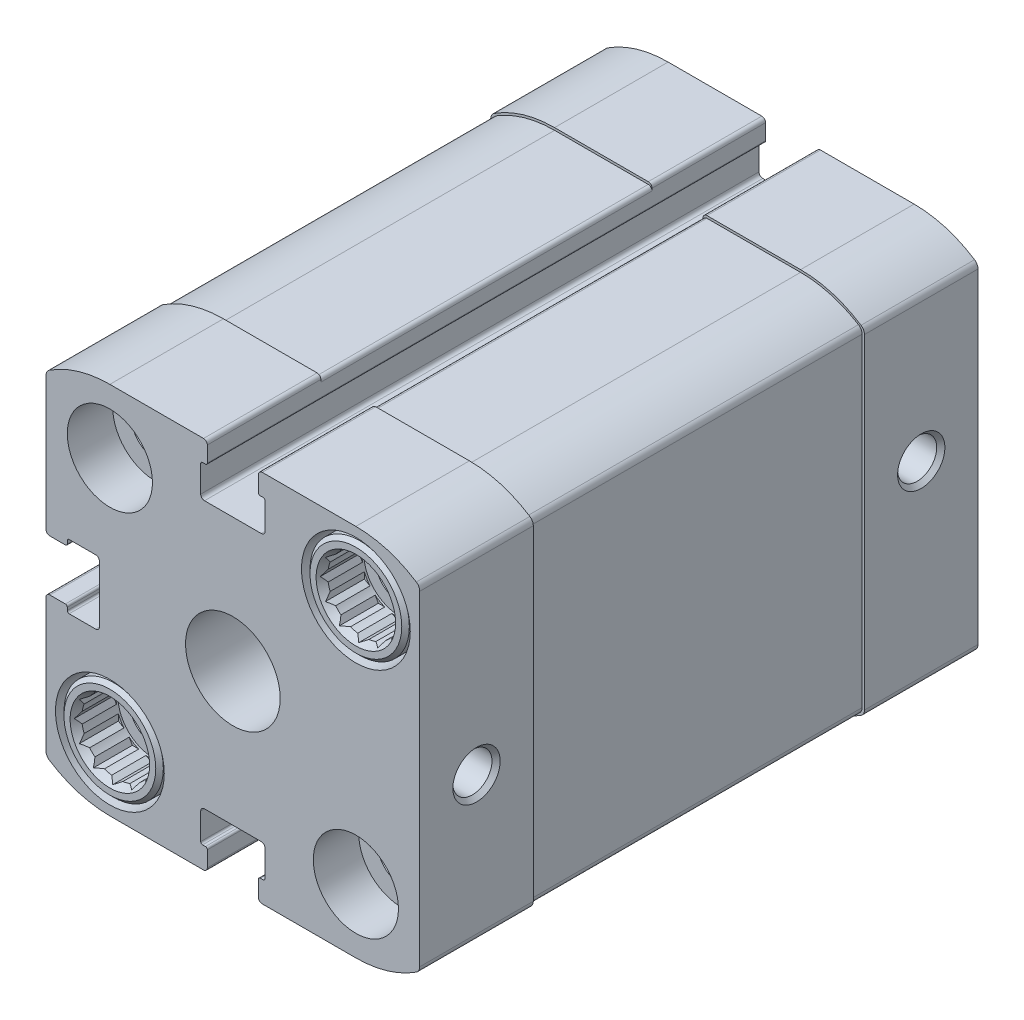
from build123d import *

# Parameters (mm, degrees)
AUFSATZ_LINEAR_AUSTRAGEN1_DEPTH = 59
SKIZZE2_W                       = 79
SKIZZE2_H                       = 79
SCHNITT_LINEAR_AUSTRAGEN1_DEPTH = 35
BOHRUNG1_D                      = 4.134
BOHRUNG1_DEPTH                  = 11
BOHRUNG1_CSINK_D                = 5
BOHRUNG1_CSINK_ANGLE            = 90
BOHRUNG2_D                      = 4.134
BOHRUNG2_DEPTH                  = 11
BOHRUNG2_CSINK_D                = 5
BOHRUNG2_CSINK_ANGLE            = 90
BOHRUNG3_D                      = 9
BOHRUNG3_DEPTH                  = 2.1
BOHRUNG4_D                      = 7
BOHRUNG4_DEPTH                  = 19.5
BOHRUNG4_CBORE_D                = 11.5
BOHRUNG4_CBORE_DEPTH            = 6.5
BOHRUNG5_D                      = 7
BOHRUNG5_DEPTH                  = 19.5
BOHRUNG5_CBORE_D                = 11.5
BOHRUNG5_CBORE_DEPTH            = 6.5
BOHRUNG6_D                      = 7
BOHRUNG6_DEPTH                  = 19.5
BOHRUNG6_CBORE_D                = 11.5
BOHRUNG6_CBORE_DEPTH            = 6.5
BOHRUNG7_D                      = 7
BOHRUNG7_DEPTH                  = 19.5
BOHRUNG7_CBORE_D                = 11.5
BOHRUNG7_CBORE_DEPTH            = 6.5
SKIZZE23_W                      = 27.5
SKIZZE23_H                      = 4.5
SKIZZE24_W                      = 2.5
SKIZZE24_H                      = 27.5
SKIZZE27_W                      = 27.5
SKIZZE27_H                      = 4.5
SKIZZE28_W                      = 2.5
SKIZZE28_H                      = 27.5
SKIZZE31_W                      = 27.5
SKIZZE31_H                      = 4.5
SKIZZE32_W                      = 2.5
SKIZZE32_H                      = 27.5
SKIZZE35_W                      = 27.5
SKIZZE35_H                      = 4.5
SKIZZE36_W                      = 2.5
SKIZZE36_H                      = 27.5
SCHNITT_LINEAR_AUSTRAGEN2_DEPTH = 4.4
SCHNITT_LINEAR_AUSTRAGEN3_DEPTH = 4.4
SCHNITT_LINEAR_AUSTRAGEN4_DEPTH = 4.4
SCHNITT_LINEAR_AUSTRAGEN5_DEPTH = 4.4


with BuildPart() as part:
    # Skizze1 → Aufsatz-Linear austragen1 (new body)
    with BuildSketch(Plane.XY):
        with BuildLine():
            Line((-19.75, -3.1), (-19.75, -17.182770664))
            ThreePointArc((-19.75, -17.182770664), (-19.653334114, -17.563980742), (-19.38669719, -17.853065796))
            ThreePointArc((-19.38669719, -17.853065796), (-16.331225765, -19.265744955), (-13, -19.75))
            Line((-13, -19.75), (-3.1, -19.75))
            ThreePointArc((-3.1, -19.75), (-2.817157288, -19.632842712), (-2.7, -19.35))
            Line((-2.7, -19.35), (-2.7, -17.7))
            ThreePointArc((-2.7, -17.7), (-2.758578644, -17.558578644), (-2.9, -17.5))
            Line((-2.9, -17.5), (-3.2, -17.5))
            ThreePointArc((-3.2, -17.5), (-3.341421356, -17.441421356), (-3.4, -17.3))
            Line((-3.4, -17.3), (-3.4, -14.5))
            ThreePointArc((-3.4, -14.5), (-3.282842712, -14.217157288), (-3, -14.1))
            Line((-3, -14.1), (3, -14.1))
            ThreePointArc((3, -14.1), (3.282842712, -14.217157288), (3.4, -14.5))
            Line((3.4, -14.5), (3.4, -17.3))
            ThreePointArc((3.4, -17.3), (3.341421356, -17.441421356), (3.2, -17.5))
            Line((3.2, -17.5), (2.9, -17.5))
            ThreePointArc((2.9, -17.5), (2.758578644, -17.558578644), (2.7, -17.7))
            Line((2.7, -17.7), (2.7, -19.35))
            ThreePointArc((2.7, -19.35), (2.817157288, -19.632842712), (3.1, -19.75))
            Line((3.1, -19.75), (13, -19.75))
            ThreePointArc((13, -19.75), (16.331225797, -19.265744946), (19.386697248, -17.853065759))
            ThreePointArc((19.386697248, -17.853065759), (19.65333413, -17.563980712), (19.75, -17.182770664))
            Line((19.75, -17.182770664), (19.75, 17.182770664))
            ThreePointArc((19.75, 17.182770664), (19.65333413, 17.563980712), (19.386697248, 17.853065759))
            ThreePointArc((19.386697248, 17.853065759), (16.331225797, 19.265744946), (13, 19.75))
            Line((13, 19.75), (3.1, 19.75))
            ThreePointArc((3.1, 19.75), (2.817157288, 19.632842712), (2.7, 19.35))
            Line((2.7, 19.35), (2.7, 17.7))
            ThreePointArc((2.7, 17.7), (2.758578644, 17.558578644), (2.9, 17.5))
            Line((2.9, 17.5), (3.2, 17.5))
            ThreePointArc((3.2, 17.5), (3.341421356, 17.441421356), (3.4, 17.3))
            Line((3.4, 17.3), (3.4, 14.5))
            ThreePointArc((3.4, 14.5), (3.282842712, 14.217157288), (3, 14.1))
            Line((3, 14.1), (-3, 14.1))
            ThreePointArc((-3, 14.1), (-3.282842712, 14.217157288), (-3.4, 14.5))
            Line((-3.4, 14.5), (-3.4, 17.3))
            ThreePointArc((-3.4, 17.3), (-3.341421356, 17.441421356), (-3.2, 17.5))
            Line((-3.2, 17.5), (-2.9, 17.5))
            ThreePointArc((-2.9, 17.5), (-2.758578644, 17.558578644), (-2.7, 17.7))
            Line((-2.7, 17.7), (-2.7, 19.35))
            ThreePointArc((-2.7, 19.35), (-2.817157288, 19.632842712), (-3.1, 19.75))
            Line((-3.1, 19.75), (-13, 19.75))
            ThreePointArc((-13, 19.75), (-16.331225797, 19.265744946), (-19.386697248, 17.853065759))
            ThreePointArc((-19.386697248, 17.853065759), (-19.65333413, 17.563980712), (-19.75, 17.182770664))
            Line((-19.75, 17.182770664), (-19.75, 3.1))
            ThreePointArc((-19.75, 3.1), (-19.632842712, 2.817157288), (-19.35, 2.7))
            Line((-19.35, 2.7), (-17.7, 2.7))
            ThreePointArc((-17.7, 2.7), (-17.558578644, 2.758578644), (-17.5, 2.9))
            Line((-17.5, 2.9), (-17.5, 3.2))
            ThreePointArc((-17.5, 3.2), (-17.441421356, 3.341421356), (-17.3, 3.4))
            Line((-17.3, 3.4), (-14.5, 3.4))
            ThreePointArc((-14.5, 3.4), (-14.217157288, 3.282842712), (-14.1, 3))
            Line((-14.1, 3), (-14.1, -3))
            ThreePointArc((-14.1, -3), (-14.217157288, -3.282842712), (-14.5, -3.4))
            Line((-14.5, -3.4), (-17.3, -3.4))
            ThreePointArc((-17.3, -3.4), (-17.441421356, -3.341421356), (-17.5, -3.2))
            Line((-17.5, -3.2), (-17.5, -2.9))
            ThreePointArc((-17.5, -2.9), (-17.558578644, -2.758578644), (-17.7, -2.7))
            Line((-17.7, -2.7), (-19.35, -2.7))
            ThreePointArc((-19.35, -2.7), (-19.632842712, -2.817157288), (-19.75, -3.1))
        make_face()
    extrude(amount=-AUFSATZ_LINEAR_AUSTRAGEN1_DEPTH)

    # Skizze2 → Schnitt-Linear austragen1 (cut)
    with BuildSketch(Plane.XY.offset(-12)):
        Rectangle(SKIZZE2_W, SKIZZE2_H)
        with BuildLine():
            Line((-19.5, -3.1), (-19.5, -17.090855719))
            ThreePointArc((-19.5, -17.090855719), (-19.39809702, -17.481573713), (-19.118348624, -17.772753387))
            ThreePointArc((-19.118348624, -17.772753387), (-16.178740739, -19.059911514), (-13, -19.5))
            Line((-13, -19.5), (-3.1, -19.5))
            ThreePointArc((-3.1, -19.5), (-2.817157288, -19.382842712), (-2.7, -19.1))
            Line((-2.7, -19.1), (-2.7, -17.65))
            ThreePointArc((-2.7, -17.65), (-2.743933983, -17.543933983), (-2.85, -17.5))
            Line((-2.85, -17.5), (-3.2, -17.5))
            ThreePointArc((-3.2, -17.5), (-3.341421356, -17.441421356), (-3.4, -17.3))
            Line((-3.4, -17.3), (-3.4, -14.5))
            ThreePointArc((-3.4, -14.5), (-3.282842712, -14.217157288), (-3, -14.1))
            Line((-3, -14.1), (3, -14.1))
            ThreePointArc((3, -14.1), (3.282842712, -14.217157288), (3.4, -14.5))
            Line((3.4, -14.5), (3.4, -17.3))
            ThreePointArc((3.4, -17.3), (3.341421356, -17.441421356), (3.2, -17.5))
            Line((3.2, -17.5), (2.85, -17.5))
            ThreePointArc((2.85, -17.5), (2.743933983, -17.543933983), (2.7, -17.65))
            Line((2.7, -17.65), (2.7, -19.1))
            ThreePointArc((2.7, -19.1), (2.817157288, -19.382842712), (3.1, -19.5))
            Line((3.1, -19.5), (13, -19.5))
            ThreePointArc((13, -19.5), (16.178740739, -19.059911514), (19.118348624, -17.772753387))
            ThreePointArc((19.118348624, -17.772753387), (19.39809702, -17.481573713), (19.5, -17.090855719))
            Line((19.5, -17.090855719), (19.5, 17.090855719))
            ThreePointArc((19.5, 17.090855719), (19.39809702, 17.481573713), (19.118348624, 17.772753387))
            ThreePointArc((19.118348624, 17.772753387), (16.178740739, 19.059911514), (13, 19.5))
            Line((13, 19.5), (3.1, 19.5))
            ThreePointArc((3.1, 19.5), (2.817157288, 19.382842712), (2.7, 19.1))
            Line((2.7, 19.1), (2.7, 17.65))
            ThreePointArc((2.7, 17.65), (2.743933983, 17.543933983), (2.85, 17.5))
            Line((2.85, 17.5), (3.2, 17.5))
            ThreePointArc((3.2, 17.5), (3.341421356, 17.441421356), (3.4, 17.3))
            Line((3.4, 17.3), (3.4, 14.5))
            ThreePointArc((3.4, 14.5), (3.282842712, 14.217157288), (3, 14.1))
            Line((3, 14.1), (-3, 14.1))
            ThreePointArc((-3, 14.1), (-3.282842712, 14.217157288), (-3.4, 14.5))
            Line((-3.4, 14.5), (-3.4, 17.3))
            ThreePointArc((-3.4, 17.3), (-3.341421356, 17.441421356), (-3.2, 17.5))
            Line((-3.2, 17.5), (-2.85, 17.5))
            ThreePointArc((-2.85, 17.5), (-2.743933983, 17.543933983), (-2.7, 17.65))
            Line((-2.7, 17.65), (-2.7, 19.1))
            ThreePointArc((-2.7, 19.1), (-2.817157288, 19.382842712), (-3.1, 19.5))
            Line((-3.1, 19.5), (-13, 19.5))
            ThreePointArc((-13, 19.5), (-16.178740739, 19.059911514), (-19.118348624, 17.772753387))
            ThreePointArc((-19.118348624, 17.772753387), (-19.39809702, 17.481573713), (-19.5, 17.090855719))
            Line((-19.5, 17.090855719), (-19.5, 3.1))
            ThreePointArc((-19.5, 3.1), (-19.382842712, 2.817157288), (-19.1, 2.7))
            Line((-19.1, 2.7), (-17.65, 2.7))
            ThreePointArc((-17.65, 2.7), (-17.543933983, 2.743933983), (-17.5, 2.85))
            Line((-17.5, 2.85), (-17.5, 3.2))
            ThreePointArc((-17.5, 3.2), (-17.441421356, 3.341421356), (-17.3, 3.4))
            Line((-17.3, 3.4), (-14.5, 3.4))
            ThreePointArc((-14.5, 3.4), (-14.217157288, 3.282842712), (-14.1, 3))
            Line((-14.1, 3), (-14.1, -3))
            ThreePointArc((-14.1, -3), (-14.217157288, -3.282842712), (-14.5, -3.4))
            Line((-14.5, -3.4), (-17.3, -3.4))
            ThreePointArc((-17.3, -3.4), (-17.441421356, -3.341421356), (-17.5, -3.2))
            Line((-17.5, -3.2), (-17.5, -2.85))
            ThreePointArc((-17.5, -2.85), (-17.543933983, -2.743933983), (-17.65, -2.7))
            Line((-17.65, -2.7), (-19.1, -2.7))
            ThreePointArc((-19.1, -2.7), (-19.382842712, -2.817157288), (-19.5, -3.1))
        make_face(mode=Mode.SUBTRACT)
    extrude(amount=-SCHNITT_LINEAR_AUSTRAGEN1_DEPTH, mode=Mode.SUBTRACT)

    # Bohrung1
    with Locations(Plane(origin=(19.75, 0, 0), x_dir=(0, 0, -1), z_dir=(1, 0, 0))):
        with Locations((6, -2.6)):
            CounterSinkHole(BOHRUNG1_D / 2, BOHRUNG1_CSINK_D / 2, depth=BOHRUNG1_DEPTH, counter_sink_angle=BOHRUNG1_CSINK_ANGLE)

    # Bohrung2
    with Locations(Plane(origin=(19.75, 0, 0), x_dir=(0, 0, -1), z_dir=(1, 0, 0))):
        with Locations((53, 2.6)):
            CounterSinkHole(BOHRUNG2_D / 2, BOHRUNG2_CSINK_D / 2, depth=BOHRUNG2_DEPTH, counter_sink_angle=BOHRUNG2_CSINK_ANGLE)

    # Skizze7 → Schnitt-Rotation1 (revolve, cut)
    with BuildSketch(Plane(origin=(0, 0, 0), x_dir=(0, 0, -1), z_dir=(1, 0, 0))):
        Polygon((-12.2, 0), (-12.2, 5), (20.75, 5), (20.75, 12.5), (47, 12.5), (47, 0), align=None)
    revolve(axis=Axis((0, 0, -47), (0, 0, 1)), mode=Mode.SUBTRACT)

    # Bohrung3
    with Locations(Plane(origin=(0, 0, -59), x_dir=(-1, 0, 0), z_dir=(0, 0, -1))):
        with Locations((0, 0)):
            Hole(BOHRUNG3_D / 2, depth=BOHRUNG3_DEPTH)

    # Bohrung4
    with Locations(Plane.XY):
        with Locations((13, 13)):
            CounterBoreHole(BOHRUNG4_D / 2, BOHRUNG4_CBORE_D / 2, BOHRUNG4_CBORE_DEPTH, depth=BOHRUNG4_DEPTH)

    # Skizze12 → Rotation1 (revolve)
    with BuildSketch(Plane(origin=(13, 0, 0), x_dir=(0, 0, -1), z_dir=(1, 0, 0))):
        Polygon((0, 17.2), (0.779422863, 16.75), (4.6, 16.75), (4.6, 15.5), (5.033, 15.067), (19.5, 15.067), (19.5, 17.5), (6.5, 17.5), (6.5, 18.25), (0.4, 18.25), (0, 17.85), align=None)
    revolve(axis=Axis((13, 13, -19.5), (0, 0, 1)))

    # Bohrung5
    with Locations(Plane(origin=(0, 0, -59), x_dir=(-1, 0, 0), z_dir=(0, 0, -1))):
        with Locations((-13, -13)):
            CounterBoreHole(BOHRUNG5_D / 2, BOHRUNG5_CBORE_D / 2, BOHRUNG5_CBORE_DEPTH, depth=BOHRUNG5_DEPTH)

    # Skizze15 → Rotation2 (revolve)
    with BuildSketch(Plane(origin=(13, 0, 0), x_dir=(0, 0, -1), z_dir=(1, 0, 0))):
        Polygon((39.5, -8.5), (39.5, -10.933), (53.967, -10.933), (54.4, -10.5), (54.4, -9.25), (58.220577137, -9.25), (59, -8.8), (59, -8.15), (58.6, -7.75), (52.5, -7.75), (52.5, -8.5), align=None)
    revolve(axis=Axis((13, -13, -59), (0, 0, 1)))

    # Bohrung6
    with Locations(Plane.XY):
        with Locations((-13, -13)):
            CounterBoreHole(BOHRUNG6_D / 2, BOHRUNG6_CBORE_D / 2, BOHRUNG6_CBORE_DEPTH, depth=BOHRUNG6_DEPTH)

    # Bohrung7
    with Locations(Plane(origin=(0, 0, -59), x_dir=(-1, 0, 0), z_dir=(0, 0, -1))):
        with Locations((13, 13)):
            CounterBoreHole(BOHRUNG7_D / 2, BOHRUNG7_CBORE_D / 2, BOHRUNG7_CBORE_DEPTH, depth=BOHRUNG7_DEPTH)

    # Skizze20 → Rotation3 (revolve)
    with BuildSketch(Plane(origin=(-13, 0, 0), x_dir=(0, 0, -1), z_dir=(1, 0, 0))):
        Polygon((0, -8.8), (0.779422863, -9.25), (4.6, -9.25), (4.6, -10.5), (5.033, -10.933), (19.5, -10.933), (19.5, -8.5), (6.5, -8.5), (6.5, -7.75), (0.4, -7.75), (0, -8.15), align=None)
    revolve(axis=Axis((-13, -13, -19.5), (0, 0, 1)))

    # Skizze21 → Rotation4 (revolve)
    with BuildSketch(Plane(origin=(-13, 0, 0), x_dir=(0, 0, -1), z_dir=(1, 0, 0))):
        Polygon((39.5, 17.5), (39.5, 15.067), (53.967, 15.067), (54.4, 15.5), (54.4, 16.75), (58.220577137, 16.75), (59, 17.2), (59, 17.85), (58.6, 18.25), (52.5, 18.25), (52.5, 17.5), align=None)
    revolve(axis=Axis((-13, 13, -59), (0, 0, 1)))

    # Skizze22 → Schnitt-Rotation2 (revolve, cut)
    with BuildSketch(Plane(origin=(13, 0, 0), x_dir=(0, 0, -1), z_dir=(1, 0, 0))):
        Polygon((-0.1, -13), (-0.1, -8.5), (4.8, -8.5), (4.8, -10.5), (5.233, -10.933), (39.5, -10.933), (39.5, -13), align=None)
    revolve(axis=Axis((13, -13, -39.5), (0, 0, 1)), mode=Mode.SUBTRACT)

    # Skizze23 → Rotation5 (revolve)
    with BuildSketch(Plane(origin=(13, 0, 0), x_dir=(0, 0, -1), z_dir=(1, 0, 0))):
        with Locations((25.75, -10.75)):
            Rectangle(SKIZZE23_W, SKIZZE23_H)
    revolve(axis=Axis((13, -13, -39.5), (0, 0, 1)))

    # Skizze24 → Bohrung8 (revolve, cut)
    with BuildSketch(Plane(origin=(13, -13, -39.5), x_dir=(0, 1, 0), z_dir=(1, 0, 0))):
        with Locations((1.25, 13.75)):
            Rectangle(SKIZZE24_W, SKIZZE24_H)
    revolve(axis=Axis((13, -13, 70.5), (0, 0, -1)), mode=Mode.SUBTRACT)

    # Skizze26 → Schnitt-Rotation3 (revolve, cut)
    with BuildSketch(Plane(origin=(13, 0, 0), x_dir=(0, 0, -1), z_dir=(1, 0, 0))):
        Polygon((29.5, 13), (29.5, 15.067), (53.767, 15.067), (54.2, 15.5), (54.2, 17.5), (59.1, 17.5), (59.1, 13), align=None)
    revolve(axis=Axis((13, 13, -59.1), (0, 0, 1)), mode=Mode.SUBTRACT)

    # Skizze27 → Rotation6 (revolve)
    with BuildSketch(Plane(origin=(13, 0, 0), x_dir=(0, 0, -1), z_dir=(1, 0, 0))):
        with Locations((33.25, 15.25)):
            Rectangle(SKIZZE27_W, SKIZZE27_H)
    revolve(axis=Axis((13, 13, -47), (0, 0, 1)))

    # Skizze28 → Bohrung9 (revolve, cut)
    with BuildSketch(Plane(origin=(13, 13, -47), x_dir=(0, 1, 0), z_dir=(1, 0, 0))):
        with Locations((1.25, 13.75)):
            Rectangle(SKIZZE28_W, SKIZZE28_H)
    revolve(axis=Axis((13, 13, 63), (0, 0, -1)), mode=Mode.SUBTRACT)

    # Skizze30 → Schnitt-Rotation4 (revolve, cut)
    with BuildSketch(Plane(origin=(-13, 0, 0), x_dir=(0, 0, -1), z_dir=(1, 0, 0))):
        Polygon((-0.1, 13), (-0.1, 17.5), (4.8, 17.5), (4.8, 15.5), (5.233, 15.067), (39.5, 15.067), (39.5, 13), align=None)
    revolve(axis=Axis((-13, 13, -39.5), (0, 0, 1)), mode=Mode.SUBTRACT)

    # Skizze31 → Rotation7 (revolve)
    with BuildSketch(Plane(origin=(-13, 0, 0), x_dir=(0, 0, -1), z_dir=(1, 0, 0))):
        with Locations((25.75, 15.25)):
            Rectangle(SKIZZE31_W, SKIZZE31_H)
    revolve(axis=Axis((-13, 13, -39.5), (0, 0, 1)))

    # Skizze32 → Bohrung10 (revolve, cut)
    with BuildSketch(Plane(origin=(-13, 13, -39.5), x_dir=(0, 1, 0), z_dir=(1, 0, 0))):
        with Locations((1.25, 13.75)):
            Rectangle(SKIZZE32_W, SKIZZE32_H)
    revolve(axis=Axis((-13, 13, 70.5), (0, 0, -1)), mode=Mode.SUBTRACT)

    # Skizze34 → Schnitt-Rotation5 (revolve, cut)
    with BuildSketch(Plane(origin=(-13, 0, 0), x_dir=(0, 0, -1), z_dir=(1, 0, 0))):
        Polygon((29.5, -13), (29.5, -10.933), (53.767, -10.933), (54.2, -10.5), (54.2, -8.5), (59.1, -8.5), (59.1, -13), align=None)
    revolve(axis=Axis((-13, -13, -59.1), (0, 0, 1)), mode=Mode.SUBTRACT)

    # Skizze35 → Rotation8 (revolve)
    with BuildSketch(Plane(origin=(-13, 0, 0), x_dir=(0, 0, -1), z_dir=(1, 0, 0))):
        with Locations((33.25, -10.75)):
            Rectangle(SKIZZE35_W, SKIZZE35_H)
    revolve(axis=Axis((-13, -13, -47), (0, 0, 1)))

    # Skizze36 → Bohrung11 (revolve, cut)
    with BuildSketch(Plane(origin=(-13, -13, -47), x_dir=(0, 1, 0), z_dir=(1, 0, 0))):
        with Locations((1.25, 13.75)):
            Rectangle(SKIZZE36_W, SKIZZE36_H)
    revolve(axis=Axis((-13, -13, 63), (0, 0, -1)), mode=Mode.SUBTRACT)

    # Skizze38 → Schnitt-Linear austragen2 (cut)
    with BuildSketch(Plane.XY):
        Polygon((-17.041451884, -13), (-16.5, -13.937822174), (-16.5, -15.020725942), (-15.562177826, -15.562177826), (-15.020725942, -16.5), (-13.937822174, -16.5), (-13, -17.041451884), (-12.062177826, -16.5), (-10.979274058, -16.5), (-10.437822174, -15.562177826), (-9.5, -15.020725942), (-9.5, -13.937822174), (-8.958548116, -13), (-9.5, -12.062177826), (-9.5, -10.979274058), (-10.437822174, -10.437822174), (-10.979274058, -9.5), (-12.062177826, -9.5), (-13, -8.958548116), (-13.937822174, -9.5), (-15.020725942, -9.5), (-15.562177826, -10.437822174), (-16.5, -10.979274058), (-16.5, -12.062177826), align=None)
    extrude(amount=-SCHNITT_LINEAR_AUSTRAGEN2_DEPTH, mode=Mode.SUBTRACT)

    # Skizze39 → Schnitt-Linear austragen3 (cut)
    with BuildSketch(Plane.XY):
        Polygon((8.958548116, 13), (9.5, 12.062177826), (9.5, 10.979274058), (10.437822174, 10.437822174), (10.979274058, 9.5), (12.062177826, 9.5), (13, 8.958548116), (13.937822174, 9.5), (15.020725942, 9.5), (15.562177826, 10.437822174), (16.5, 10.979274058), (16.5, 12.062177826), (17.041451884, 13), (16.5, 13.937822174), (16.5, 15.020725942), (15.562177826, 15.562177826), (15.020725942, 16.5), (13.937822174, 16.5), (13, 17.041451884), (12.062177826, 16.5), (10.979274058, 16.5), (10.437822174, 15.562177826), (9.5, 15.020725942), (9.5, 13.937822174), align=None)
    extrude(amount=-SCHNITT_LINEAR_AUSTRAGEN3_DEPTH, mode=Mode.SUBTRACT)

    # Skizze40 → Schnitt-Linear austragen4 (cut)
    with BuildSketch(Plane.XY.offset(-59)):
        Polygon((-17.041451884, 13), (-16.5, 12.062177826), (-16.5, 10.979274058), (-15.562177826, 10.437822174), (-15.020725942, 9.5), (-13.937822174, 9.5), (-13, 8.958548116), (-12.062177826, 9.5), (-10.979274058, 9.5), (-10.437822174, 10.437822174), (-9.5, 10.979274058), (-9.5, 12.062177826), (-8.958548116, 13), (-9.5, 13.937822174), (-9.5, 15.020725942), (-10.437822174, 15.562177826), (-10.979274058, 16.5), (-12.062177826, 16.5), (-13, 17.041451884), (-13.937822174, 16.5), (-15.020725942, 16.5), (-15.562177826, 15.562177826), (-16.5, 15.020725942), (-16.5, 13.937822174), align=None)
    extrude(amount=SCHNITT_LINEAR_AUSTRAGEN4_DEPTH, mode=Mode.SUBTRACT)

    # Skizze41 → Schnitt-Linear austragen5 (cut)
    with BuildSketch(Plane.XY.offset(-59)):
        Polygon((8.958548116, -13), (9.5, -13.937822174), (9.5, -15.020725942), (10.437822174, -15.562177826), (10.979274058, -16.5), (12.062177826, -16.5), (13, -17.041451884), (13.937822174, -16.5), (15.020725942, -16.5), (15.562177826, -15.562177826), (16.5, -15.020725942), (16.5, -13.937822174), (17.041451884, -13), (16.5, -12.062177826), (16.5, -10.979274058), (15.562177826, -10.437822174), (15.020725942, -9.5), (13.937822174, -9.5), (13, -8.958548116), (12.062177826, -9.5), (10.979274058, -9.5), (10.437822174, -10.437822174), (9.5, -10.979274058), (9.5, -12.062177826), align=None)
    extrude(amount=SCHNITT_LINEAR_AUSTRAGEN5_DEPTH, mode=Mode.SUBTRACT)


solid = part.part
